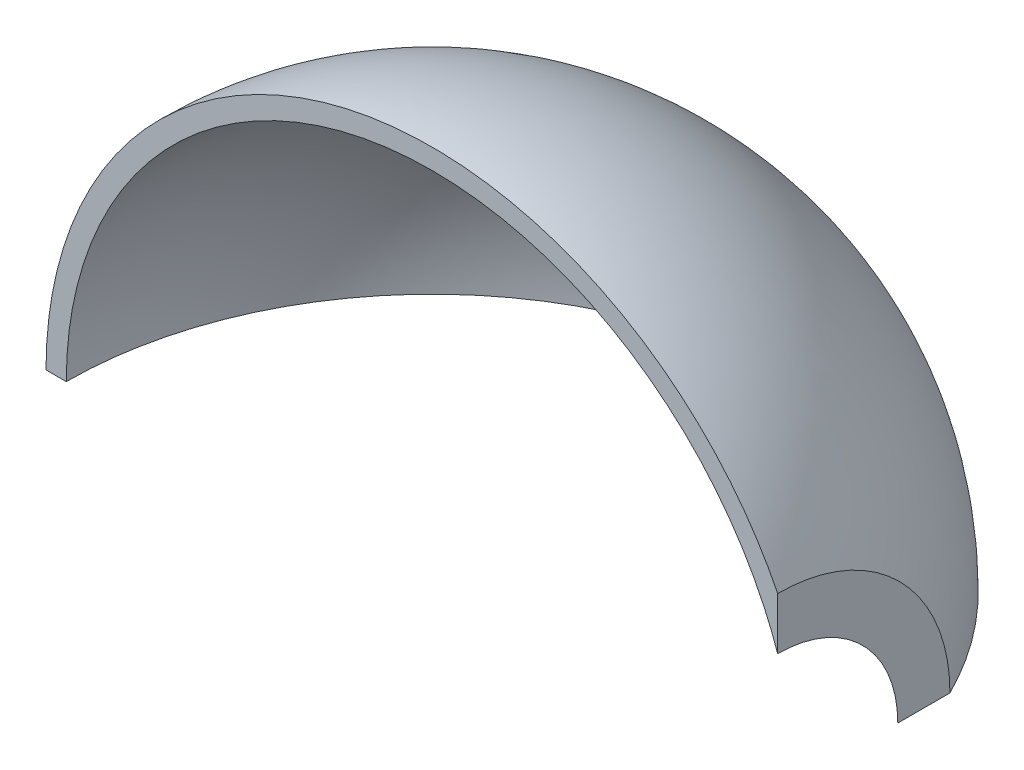
from build123d import *

# Parameters (mm, degrees)
REVOLVE1_ANGLE = 90


with BuildPart() as part:
    # Sketch2 → Revolve1 (revolve)
    with BuildSketch(Plane.XY):
        with BuildLine():
            Line((-95.25, 0), (-90.25, 0))
            add(Edge.make_bspline(
                [(-90.25, 0), (-90.24999956, 3.705354147), (-89.884113391, 10.389197128), (-88.46236209, 19.576943244), (-85.063392765, 30.952475888), (-80.776913123, 40.79991206), (-75.595472533, 49.748064286), (-69.426948495, 58.046917281), (-62.351956617, 65.58795107), (-54.462894895, 72.272669641), (-45.86276068, 78.013801241), (-36.663824141, 82.736389121), (-26.98620007, 86.378765771), (-16.956231513, 88.893375525), (-6.458062805, 90.279986509), (4.381639822, 90.424532912), (15.408779036, 89.225149901), (25.062670503, 86.927280308), (33.078163559, 84.108541143), (39.532842427, 81.213032348), (44.541393892, 78.57777362), (50.583464016, 74.898095255), (57.446252635, 69.888605097), (64.80769511, 63.233849539), (70.817226136, 56.248401441), (74.908966512, 50.473176675), (77.511967579, 46.263269961), (78.923312577, 43.81217214), (80.090453969, 41.629785978), (81.041590991, 39.733885887), (81.801034864, 38.137713564), (82.388421596, 36.851673331), (82.95580586, 35.555952313), (83.434002469, 34.415847835), (83.831810225, 33.431244506), (84.154352436, 32.608443295), (84.374087914, 32.035121351), (84.560091479, 31.539898039), (84.747097746, 31.033354346), (84.935522763, 30.514292297), (85.08976101, 30.080960875), (85.196874544, 29.77551452), (85.25, 29.622626488)],
                knots=[0, 0, 0, 0, 0, 0.053573246, 0.096637017, 0.133928187, 0.171222227, 0.208516896, 0.245811781, 0.283106382, 0.320401143, 0.357695858, 0.394990842, 0.432285694, 0.469580498, 0.506875342, 0.547762112, 0.58864884, 0.629535582, 0.649978985, 0.670422387, 0.69086584, 0.711309292, 0.752195771, 0.793082194, 0.833968592, 0.844190413, 0.854412234, 0.864634055, 0.874855876, 0.879966821, 0.885077766, 0.890188711, 0.895299656, 0.9004106, 0.902966073, 0.905521545, 0.908077018, 0.909354754, 0.91063249, 0.913187963, 0.915743435, 0.915743435, 0.915743435, 0.915743435, 0.915743435], degree=4))
            Line((85.25, 29.622626488), (85.25, 42.485291572))
            add(Edge.make_bspline(
                [(-95.25, 0), (-95.249999772, 3.886715338), (-94.87489846, 10.781056894), (-93.422805875, 20.327030651), (-89.934883822, 32.205092602), (-85.525432348, 42.517137325), (-80.105220698, 52.014057607), (-73.634911908, 60.829345788), (-66.199345822, 68.847341738), (-57.896017155, 75.962892863), (-48.833776514, 82.082714483), (-39.131425291, 87.126582048), (-30.193045783, 90.540659881), (-22.29467995, 92.721256275), (-15.598168302, 94.030154619), (-10.189793665, 94.768881698), (-3.425272172, 95.300804482), (4.692635562, 95.322359221), (14.10682621, 94.455989976), (24.66450784, 92.263744831), (34.907760986, 88.89535784), (43.481245013, 84.956462986), (50.473758849, 80.907881317), (56.026638816, 77.108020077), (60.290264599, 73.822184832), (64.361582567, 70.300907909), (68.227615414, 66.555414975), (71.419976881, 63.092382127), (74.013007435, 59.999286736), (76.074932036, 57.342679924), (77.465204448, 55.443015969), (78.618129509, 53.787284623), (79.552764993, 52.389625272), (80.284525731, 51.261226761), (81.000495784, 50.122172839), (81.699884439, 48.973989549), (82.383863979, 47.814271345), (83.049586506, 46.648690306), (83.621083166, 45.613685903), (84.095220295, 44.73147923), (84.446120765, 44.063296503), (84.686172548, 43.59891243), (84.925575044, 43.130508872), (85.078918139, 42.827249783), (85.181721924, 42.622296774), (85.25, 42.485291572)],
                knots=[0, 0, 0, 0, 0, 0.05546633, 0.098387118, 0.13731241, 0.176239098, 0.215166578, 0.254094254, 0.293022159, 0.331949944, 0.37087771, 0.409805439, 0.448733219, 0.468197121, 0.487661023, 0.507124932, 0.526588841, 0.564977071, 0.603365275, 0.641753579, 0.680141773, 0.718529797, 0.737723979, 0.756918162, 0.77611231, 0.795306459, 0.814500444, 0.833694429, 0.843291399, 0.852888369, 0.862485338, 0.867283823, 0.872082308, 0.87688095, 0.881679591, 0.886478233, 0.891276875, 0.896075517, 0.900874159, 0.90327348, 0.905672801, 0.906872461, 0.908072122, 0.910471443, 0.910471443, 0.910471443, 0.910471443, 0.910471443], degree=4))
        make_face()
    revolve(axis=Axis((-95.25, 0, 0), (-1, 0, 0)), revolution_arc=REVOLVE1_ANGLE)


solid = part.part
